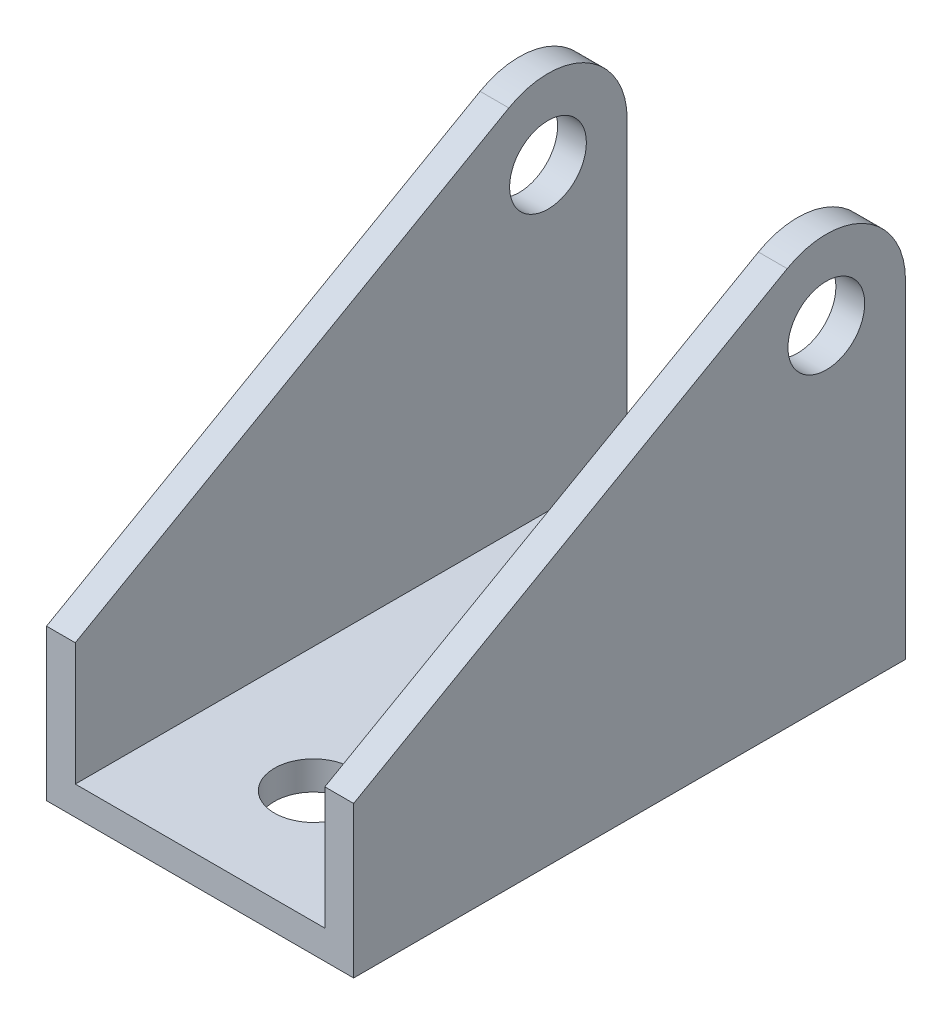
from build123d import *

# Parameters (mm, degrees)
SKETCH1_R               = 4.064
BOSS_EXTRUDE1_DEPTH     = 32.512
SKETCH2_W               = 26.416
SKETCH2_H               = 40.132
CUT_EXTRUDE1_DEPTH      = 59.42
SKETCH3_R               = 4.125
CUT_EXTRUDE3_DEPTH      = 44.18
CUT_EXTRUDE3_DEPTH_BACK = 35.052


with BuildPart() as part:
    # Sketch1 → Boss-Extrude1 (new body)
    with BuildSketch(Plane(origin=(0, 0, 0), x_dir=(0, 0, -1), z_dir=(1, 0, 0))):
        with BuildLine():
            Line((0, 16.002), (45.896514256, 42.085387724))
            ThreePointArc((45.896514256, 42.085387724), (54.253684434, 42.0427173), (58.42, 34.798))
            Line((58.42, 34.798), (58.42, 0))
            Line((58.42, 0), (0, 0))
            Line((0, 0), (0, 16.002))
        make_face()
        with Locations((50.038, 34.798)):
            Circle(SKETCH1_R, mode=Mode.SUBTRACT)
    extrude(amount=-BOSS_EXTRUDE1_DEPTH)

    # Sketch2 → Cut-Extrude1 (cut, through all)
    with BuildSketch(Plane.XY):
        with Locations((-16.256, 23.114)):
            Rectangle(SKETCH2_W, SKETCH2_H)
    extrude(amount=-CUT_EXTRUDE1_DEPTH, mode=Mode.SUBTRACT)

    # Sketch3 → Cut-Extrude3 (cut, two sides)
    with BuildSketch(Plane(origin=(0, 0, 0), x_dir=(1, 0, 0), z_dir=(0, 1, 0))) as cut_extrude3_sk:
        with Locations(Location((-16.256, 12, 0), (0, 0, 90))):  # turned: the seam where the file's is
            Circle(SKETCH3_R)
        with BuildLine():
            Line((-20.574, 48.42), (-20.574, 58.42))
            Line((-20.574, 58.42), (-11.938, 58.42))
            Line((-11.938, 58.42), (-11.938, 48.42))
            ThreePointArc((-11.938, 48.42), (-16.256, 44.102), (-20.574, 48.42))
        make_face()
    extrude(amount=CUT_EXTRUDE3_DEPTH, mode=Mode.SUBTRACT)
    extrude(cut_extrude3_sk.sketch, amount=-CUT_EXTRUDE3_DEPTH_BACK, mode=Mode.SUBTRACT)


solid = part.part
